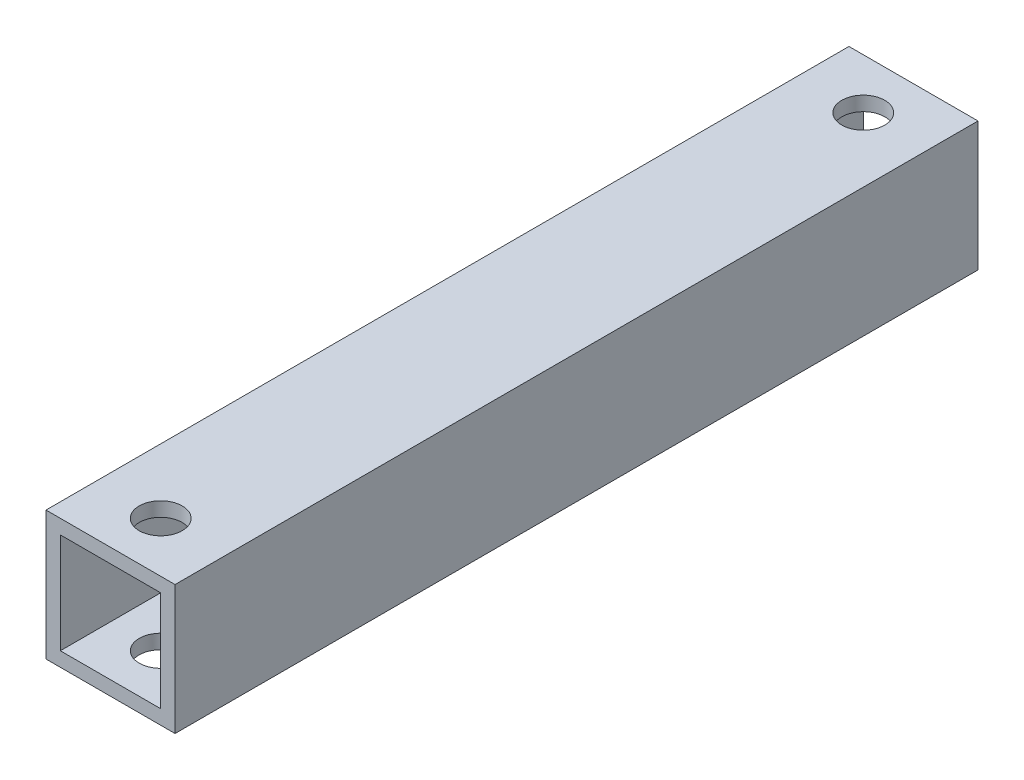
from build123d import *

# Parameters (mm, degrees)
SKETCH_1_W          = 9
SKETCH_1_H          = 9
EXTRUDE_1_DEPTH     = 56
SKETCH_2_W          = 7
SKETCH_2_H          = 7
CUT_EXTRUDE_1_DEPTH = 56
SKETCH_3_R          = 1.5
CUT_EXTRUDE_2_DEPTH = 56


with BuildPart() as part:
    # ｽｹｯﾁ1 → ﾎﾞｽ - 押し出し1 (new body)
    with BuildSketch(Plane.XY):
        Rectangle(SKETCH_1_W, SKETCH_1_H)
    extrude(amount=EXTRUDE_1_DEPTH)

    # ｽｹｯﾁ2 → ｶｯﾄ - 押し出し1 (cut)
    with BuildSketch(Plane.XY.offset(56)):
        Rectangle(SKETCH_2_W, SKETCH_2_H)
    extrude(amount=-CUT_EXTRUDE_1_DEPTH, mode=Mode.SUBTRACT)

    # ｽｹｯﾁ3 → ｶｯﾄ - 押し出し2 (cut)
    with BuildSketch(Plane(origin=(0, 4.5, 0), x_dir=(1, 0, 0), z_dir=(0, 1, 0))):
        with Locations((0, -3.5)):
            Circle(SKETCH_3_R)
        with Locations((0, -52.5)):
            Circle(SKETCH_3_R)
    extrude(amount=-CUT_EXTRUDE_2_DEPTH, mode=Mode.SUBTRACT)


solid = part.part
